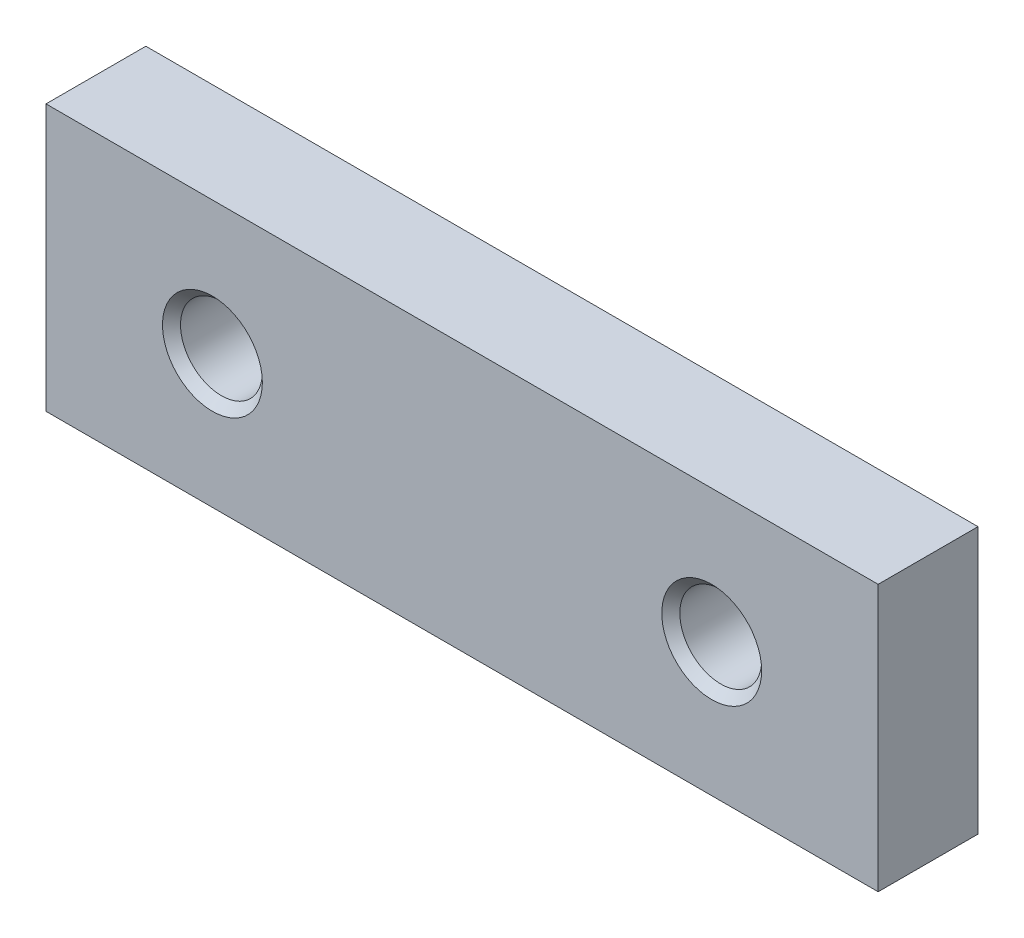
from build123d import *

# Parameters (mm, degrees)
BOSS_EXTRUDE1_DEPTH      = 3
BOSS_EXTRUDE1_DEPTH_BACK = 3
SKETCH1_W                = 50
SKETCH1_H                = 16


with BuildPart() as part:
    # Sketch1 → Boss-Extrude1 (new, two sides: drawn at the far end of the back side and taken through both)
    with BuildSketch(Plane.XY.offset(-BOSS_EXTRUDE1_DEPTH_BACK)):
        with Locations((15, 0)):
            Rectangle(SKETCH1_W, SKETCH1_H)
    extrude(amount=BOSS_EXTRUDE1_DEPTH + BOSS_EXTRUDE1_DEPTH_BACK)

    # Sketch2 → Cut-Revolve1 (revolve, cut)
    with BuildSketch(Plane(origin=(0, 0, 0), x_dir=(0, 0, -1), z_dir=(1, 0, 0))):
        Polygon((-3, 0), (-3, 3), (-2.4585, 2.4585), (2.4585, 2.4585), (3, 3), (3, 0), align=None)
    revolve(axis=Axis((0, 0, -3), (0, 0, 1)), mode=Mode.SUBTRACT)

    # Sketch3 → Cut-Revolve2 (revolve, cut)
    with BuildSketch(Plane(origin=(30, 0, 0), x_dir=(0, 0, -1), z_dir=(1, 0, 0))):
        Polygon((-3, 0), (-3, 3), (-2.4585, 2.4585), (2.4585, 2.4585), (3, 3), (3, 0), align=None)
    revolve(axis=Axis((30, 0, -3), (0, 0, 1)), mode=Mode.SUBTRACT)


solid = part.part
